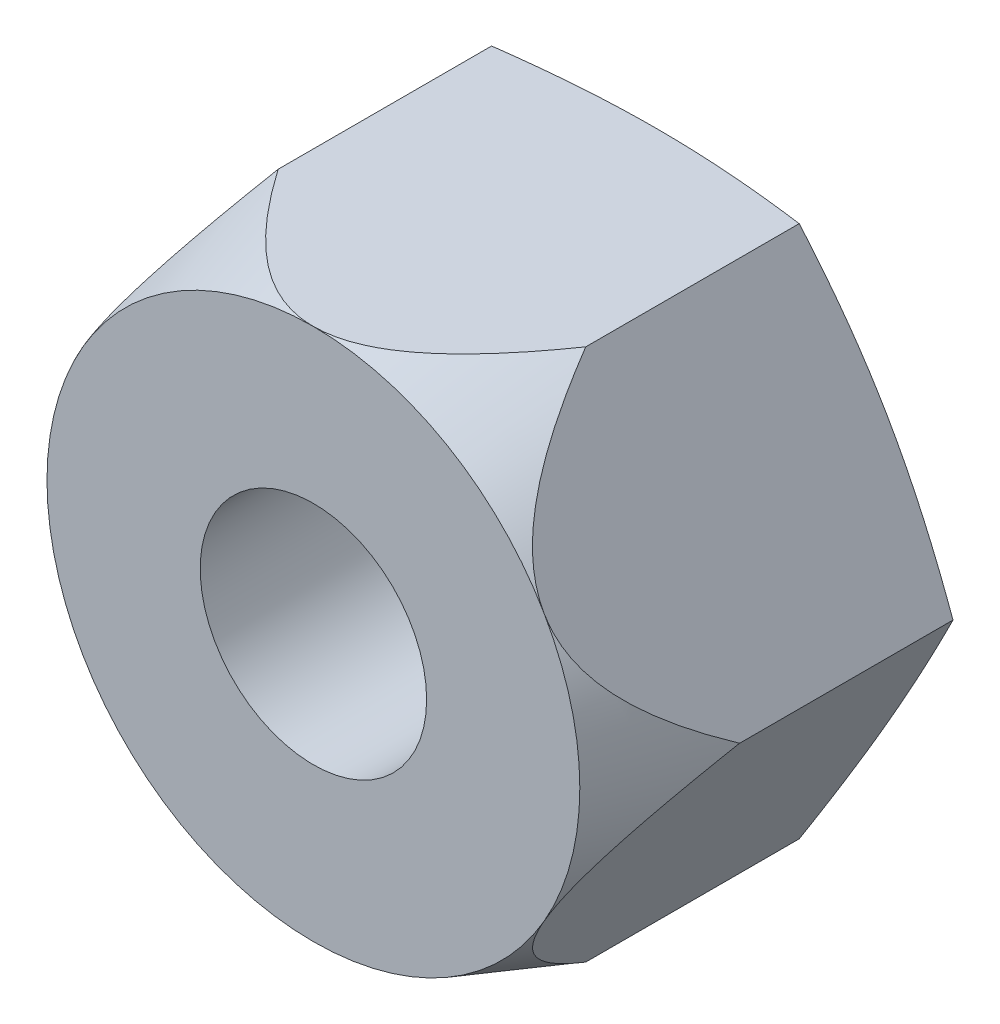
from build123d import *

# Parameters (mm, degrees)
BASENUT_DEPTH   = 5.3
SKETCH3_R       = 1.7
HOLE_DEPTH      = 6.3
ENDCHAMFER_SIZE = 0.485714286


with BuildPart() as part:
    # Sketch1 → BaseNut (new body)
    with BuildSketch(Plane.XY):
        Polygon((2.309401077, -4), (4.618802154, 0), (2.309401077, 4), (-2.309401077, 4), (-4.618802154, 0), (-2.309401077, -4), align=None)
    extrude(amount=-BASENUT_DEPTH)

    # Sketch2 → Double-Chamfer (revolve, cut)
    with BuildSketch(Plane(origin=(0.481162538, 0, -5.099964691), x_dir=(0, 0, -1), z_dir=(0, -1, 0))):
        Polygon((-0.115823776, 4.137639616), (0.200035309, 4.137639616), (0.200035309, 2.958837462), align=None)
        Polygon((-5.099964691, 4.137639616), (-3.319964691, 4.137639616), (-5.099964691, 3.518837462), align=None)
    revolve(axis=Axis((0, 0, -4.462865094), (0, 0, 1)), mode=Mode.SUBTRACT)

    # Sketch3 → Hole (cut, through all)
    with BuildSketch(Plane.XY):
        Circle(SKETCH3_R)
    extrude(amount=-HOLE_DEPTH, mode=Mode.SUBTRACT)

    # EndChamfer
    endchamfer_edges = [part.edges().sort_by_distance(p)[0] for p in [
        (-1.7, 0, -5.3),
    ]]
    chamfer(endchamfer_edges, length=ENDCHAMFER_SIZE)


solid = part.part
